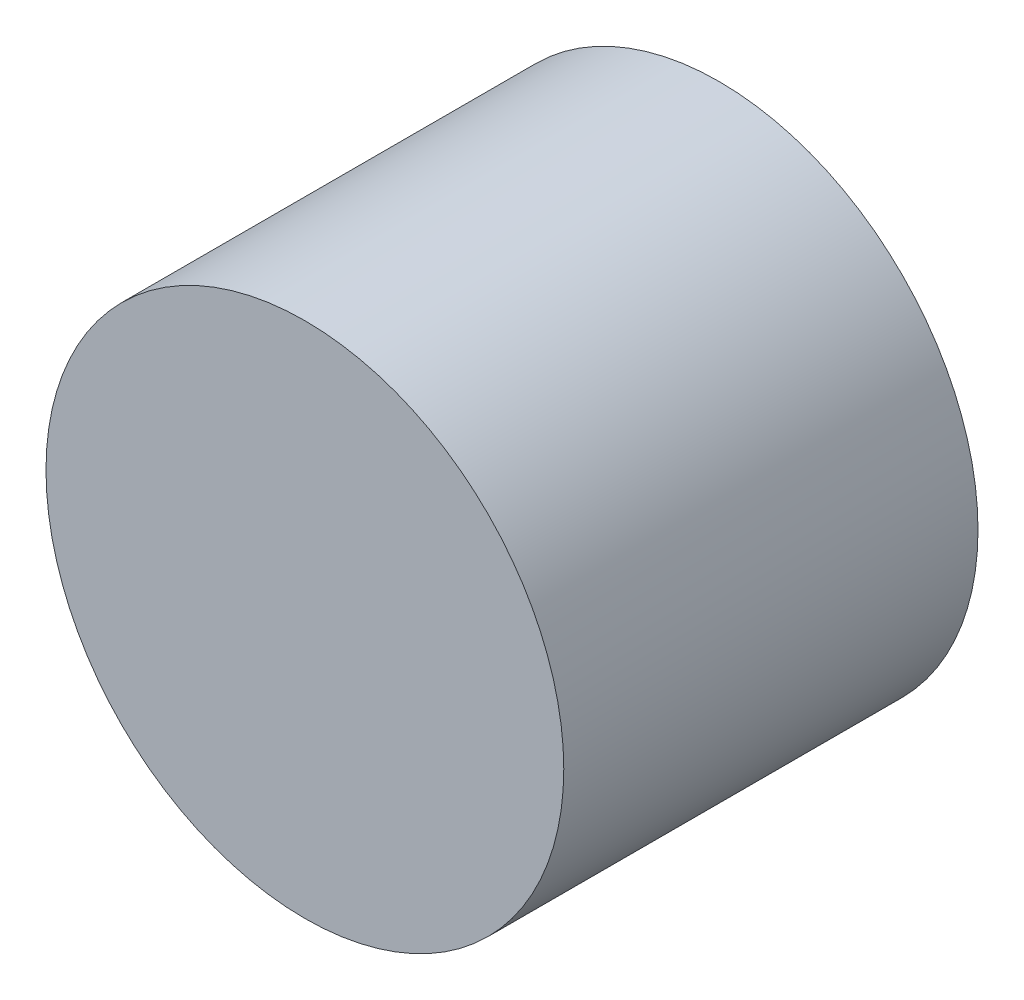
from build123d import *

# Parameters (mm, degrees)
SKETCH1_R           = 2.5
BOSS_EXTRUDE1_DEPTH = 4


with BuildPart() as part:
    # Sketch1 → Boss-Extrude1 (new body)
    with BuildSketch(Plane.XY):
        Circle(SKETCH1_R)
    extrude(amount=BOSS_EXTRUDE1_DEPTH)


solid = part.part
